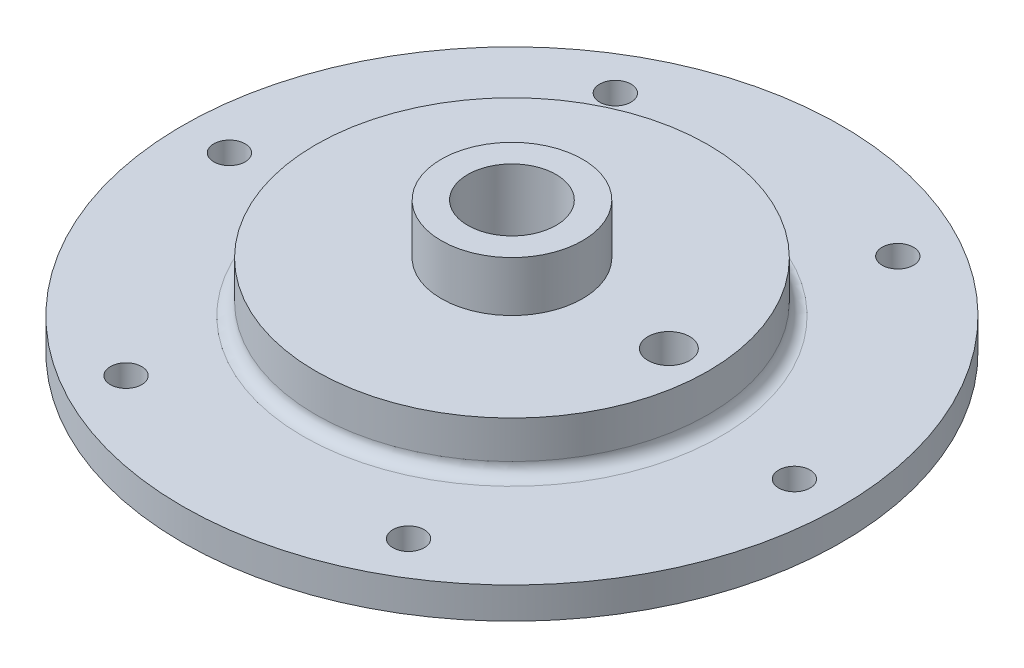
from build123d import *

# Parameters (mm, degrees)
SKETCH1_R                            = 66.675
BOSS_EXTRUDE1_DEPTH                  = 6.35
SKETCH2_R                            = 39.6875
BOSS_EXTRUDE2_DEPTH                  = 10.16
FILLET1_R                            = 2.54
SKETCH5_R                            = 23.749
CUT_EXTRUDE1_DEPTH                   = 11.557
F_1_4_0_25_DIAMETER_HOLE1_D          = 6.35
F_1_4_0_25_DIAMETER_HOLE1_DEPTH      = 6.351
CIRPATTERN1_COUNT                    = 6
SKETCH8_W                            = 5.334
SKETCH8_H                            = 2.7178
Q_0_332_DIAMETER_HOLE1_D             = 8.4328
Q_0_332_DIAMETER_HOLE1_DEPTH         = 8.89
Q_0_332_DIAMETER_HOLE1_TIP           = 2.533468714
F_3_32_0_09375_DIAMETER_HOLE1_D      = 2.38125
SKETCH16_R                           = 14.2875
BOSS_EXTRUDE3_DEPTH                  = 10.16
F_45_64_0_70313_DIAMETER_HOLE1_D     = 17.859502
F_45_64_0_70313_DIAMETER_HOLE1_DEPTH = 15.113


with BuildPart() as part:
    # Sketch1 → Boss-Extrude1 (new body)
    with BuildSketch(Plane(origin=(0, 0, 0), x_dir=(1, 0, 0), z_dir=(0, 1, 0))):
        Circle(SKETCH1_R)
    extrude(amount=BOSS_EXTRUDE1_DEPTH)

    # Sketch2 → Boss-Extrude2 (add)
    with BuildSketch(Plane(origin=(0, 6.35, 0), x_dir=(1, 0, 0), z_dir=(0, 1, 0))):
        Circle(SKETCH2_R)
    extrude(amount=BOSS_EXTRUDE2_DEPTH)

    # Fillet1
    fillet1_edges = [part.edges().sort_by_distance(p)[0] for p in [
        (-39.6875, 6.35, 0),
    ]]
    fillet(fillet1_edges, radius=FILLET1_R)

    # Sketch5 → Cut-Extrude1 (cut)
    with BuildSketch(Plane.XZ):
        Circle(SKETCH5_R)
    extrude(amount=-CUT_EXTRUDE1_DEPTH, mode=Mode.SUBTRACT)

    # 1/4 (0.25) Diameter Hole1
    with Locations(Plane(origin=(0, 6.35, 0), x_dir=(1, 0, 0), z_dir=(0, 1, 0))):
        with Locations((-57.15, 0)):
            f_1_4_0_25_diameter_hole1 = Hole(F_1_4_0_25_DIAMETER_HOLE1_D / 2, depth=F_1_4_0_25_DIAMETER_HOLE1_DEPTH)

    # CirPattern1: 1/4 (0.25) Diameter Hole1 ×6 about axis
    cirpattern1_axis = Axis((0, 0, 0), (0, 1, 0))
    for i in range(1, CIRPATTERN1_COUNT):
        add(f_1_4_0_25_diameter_hole1.rotate(cirpattern1_axis, i * 360 / CIRPATTERN1_COUNT), mode=Mode.SUBTRACT)

    # Sketch8 → Cut-Revolve1 (revolve, cut)
    with BuildSketch(Plane.XY):
        with Locations((40.2844, 1.3589)):
            Rectangle(SKETCH8_W, SKETCH8_H)
    revolve(axis=Axis((0, -1.27, 0), (0, 1, 0)), mode=Mode.SUBTRACT)

    # Q (0.332) Diameter Hole1
    with Locations(Plane(origin=(0, 16.51, 0), x_dir=(1, 0, 0), z_dir=(0, 1, 0))):
        with Locations((31.75, 0)):
            Hole(Q_0_332_DIAMETER_HOLE1_D / 2, depth=Q_0_332_DIAMETER_HOLE1_DEPTH)
            with Locations((0, 0, -(Q_0_332_DIAMETER_HOLE1_DEPTH + Q_0_332_DIAMETER_HOLE1_TIP / 2))):  # 118° drill point
                Cone(0, Q_0_332_DIAMETER_HOLE1_D / 2, Q_0_332_DIAMETER_HOLE1_TIP, mode=Mode.SUBTRACT)

    # 3/32 (0.09375) Diameter Hole1 (through all)
    with Locations(Plane(origin=(0, 0, 0), x_dir=(-1, 0, 0), z_dir=(0, -1, 0))):
        with Locations((-31.75, 0)):
            Hole(F_3_32_0_09375_DIAMETER_HOLE1_D / 2)

    # Sketch16 → Boss-Extrude3 (add)
    with BuildSketch(Plane(origin=(0, 16.51, 0), x_dir=(1, 0, 0), z_dir=(0, 1, 0))):
        Circle(SKETCH16_R)
    extrude(amount=BOSS_EXTRUDE3_DEPTH)

    # 45/64 (0.70313) Diameter Hole1
    with Locations(Plane(origin=(0, 26.67, 0), x_dir=(1, 0, 0), z_dir=(0, 1, 0))):
        with Locations((0, 0)):
            Hole(F_45_64_0_70313_DIAMETER_HOLE1_D / 2, depth=F_45_64_0_70313_DIAMETER_HOLE1_DEPTH)


solid = part.part
